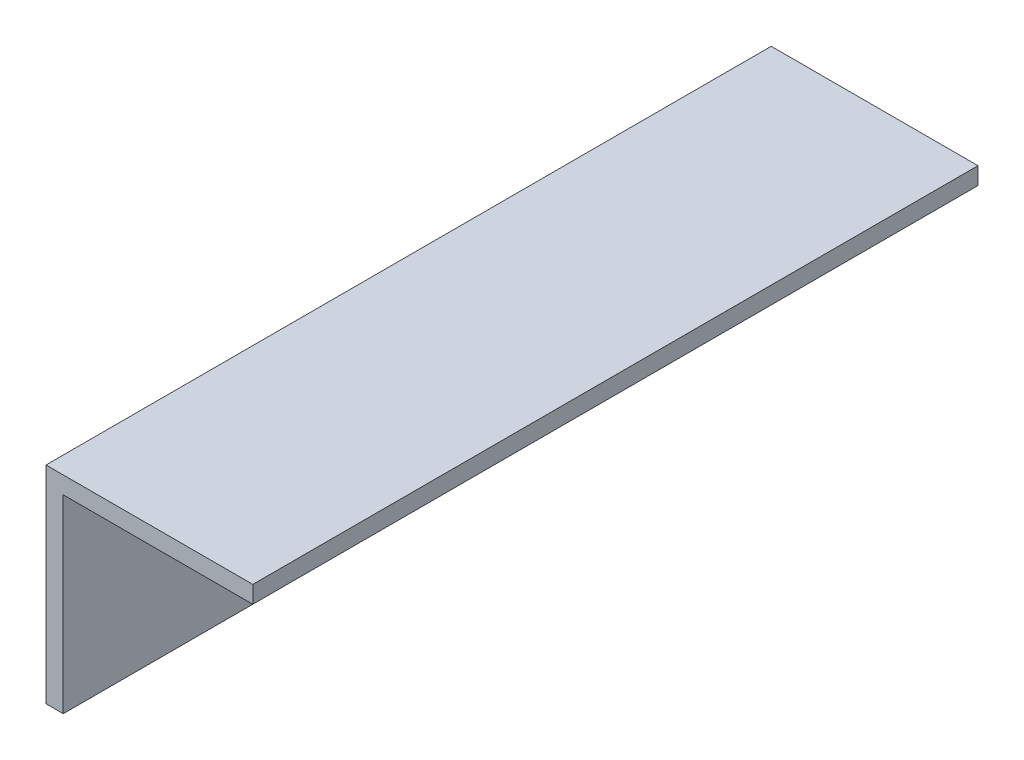
from build123d import *

# Parameters (mm, degrees)
BOSS_EXTRUDE2_DEPTH = 66.802


with BuildPart() as part:
    # Sketch1 → Boss-Extrude2 (new body)
    with BuildSketch(Plane.XY):
        Polygon((0, 0), (0, 19.05), (19.05, 19.05), (19.05, 17.4625), (1.5875, 17.4625), (1.5875, 0), align=None)
    extrude(amount=BOSS_EXTRUDE2_DEPTH)


solid = part.part
